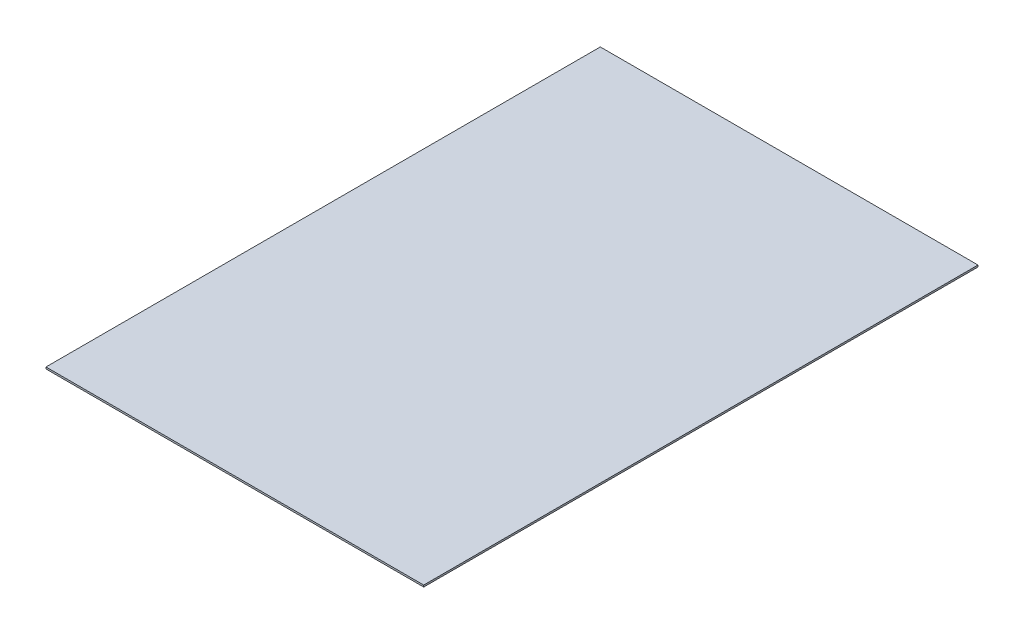
from build123d import *

# Parameters (mm, degrees)
SKETCH2_W           = 213
SKETCH2_H           = 312.59
BOSS_EXTRUDE1_DEPTH = 1


with BuildPart() as part:
    # Sketch2 → Boss-Extrude1 (new body)
    with BuildSketch(Plane(origin=(0, 0, 0), x_dir=(1, 0, 0), z_dir=(0, 1, 0))):
        with Locations((0, 156.295)):
            Rectangle(SKETCH2_W, SKETCH2_H)
    extrude(amount=-BOSS_EXTRUDE1_DEPTH)


solid = part.part
